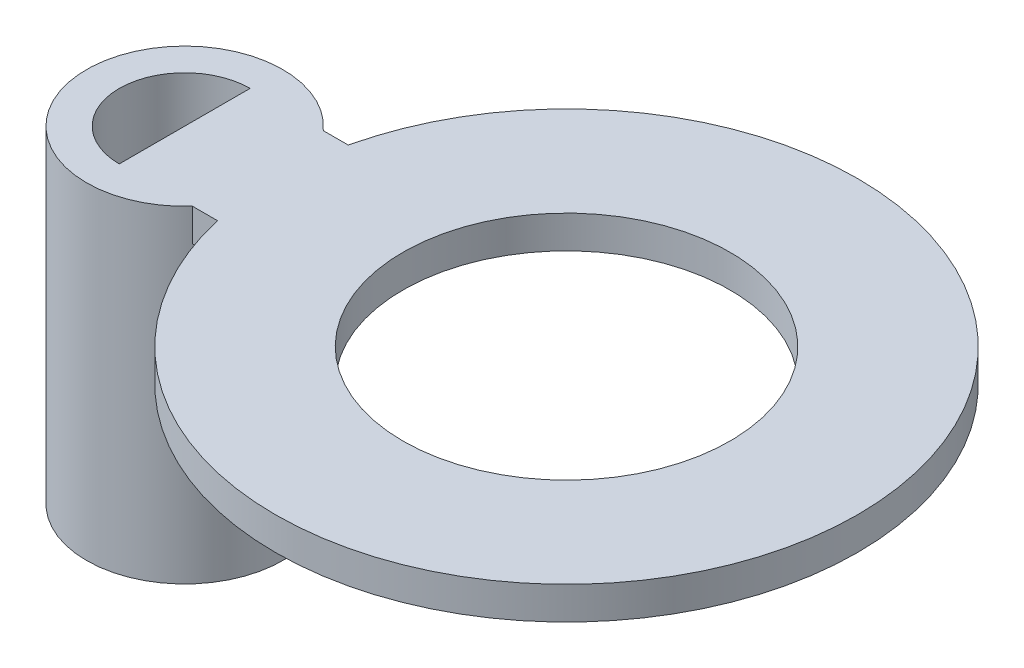
from build123d import *

# Parameters (mm, degrees)
SKETCH1_R           = 2.5
BOSS_EXTRUDE1_DEPTH = 0.5
SKETCH2_R           = 1.5
SKETCH2_R_2         = 1
BOSS_EXTRUDE2_DEPTH = 5


with BuildPart() as part:
    # Sketch1 → Boss-Extrude1 (new body)
    with BuildSketch(Plane(origin=(0, 0, 0), x_dir=(1, 0, 0), z_dir=(0, 1, 0))):
        with BuildLine():
            Line((0, -1), (0, 1))
            Line((0, 1), (1.5, 1))
            ThreePointArc((1.5, 1), (10.286184959, 0), (1.5, -1))
            Line((1.5, -1), (0, -1))
        make_face()
        with Locations((5.836184959, 0)):
            Circle(SKETCH1_R, mode=Mode.SUBTRACT)
    extrude(amount=BOSS_EXTRUDE1_DEPTH)

    # Sketch2 → Boss-Extrude2 (add)
    with BuildSketch(Plane(origin=(0.5, 0.5, 0), x_dir=(0, 0, -1), z_dir=(0, 1, 0))):
        with Locations((0, 0.5)):
            Circle(SKETCH2_R)
        with Locations((0, 0.5)):
            Circle(SKETCH2_R_2, mode=Mode.SUBTRACT)
    extrude(amount=-BOSS_EXTRUDE2_DEPTH)


solid = part.part
